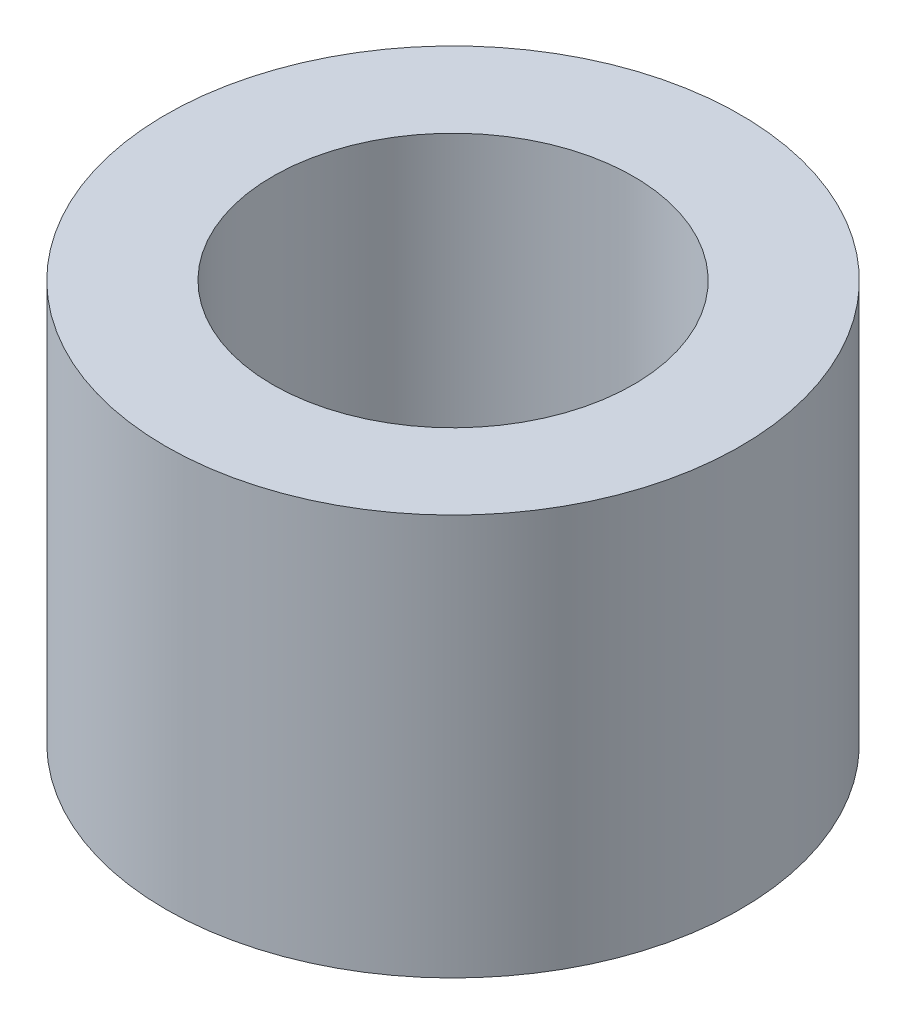
from build123d import *

# Parameters (mm, degrees)
SKETCH1_R           = 107.5
BOSS_EXTRUDE1_DEPTH = 150
SKETCH2_R           = 67.5
CUT_EXTRUDE1_DEPTH  = 151


with BuildPart() as part:
    # Sketch1 → Boss-Extrude1 (new body)
    with BuildSketch(Plane(origin=(0, 0, 0), x_dir=(1, 0, 0), z_dir=(0, 1, 0))):
        Circle(SKETCH1_R)
    extrude(amount=BOSS_EXTRUDE1_DEPTH)

    # Sketch2 → Cut-Extrude1 (cut, through all)
    with BuildSketch(Plane(origin=(0, 150, 0), x_dir=(1, 0, 0), z_dir=(0, 1, 0))):
        Circle(SKETCH2_R)
    extrude(amount=-CUT_EXTRUDE1_DEPTH, mode=Mode.SUBTRACT)


solid = part.part
